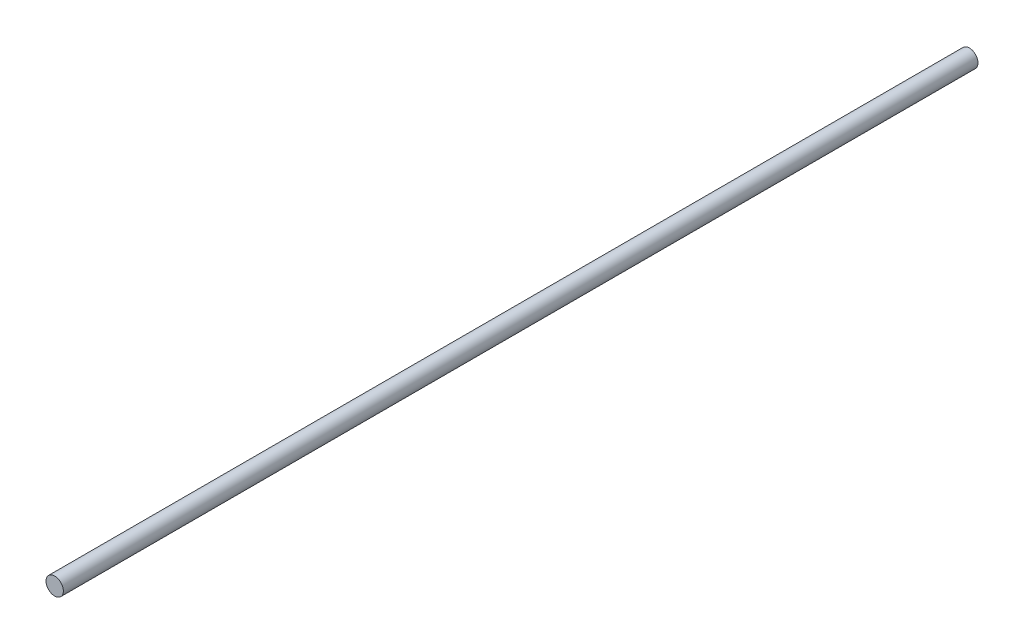
from build123d import *

# Parameters (mm, degrees)
SKETCH1_R           = 19.05
BOSS_EXTRUDE1_DEPTH = 2006.6


with BuildPart() as part:
    # Sketch1 → Boss-Extrude1 (new body)
    with BuildSketch(Plane.XY):
        Circle(SKETCH1_R)
    extrude(amount=BOSS_EXTRUDE1_DEPTH)


solid = part.part
